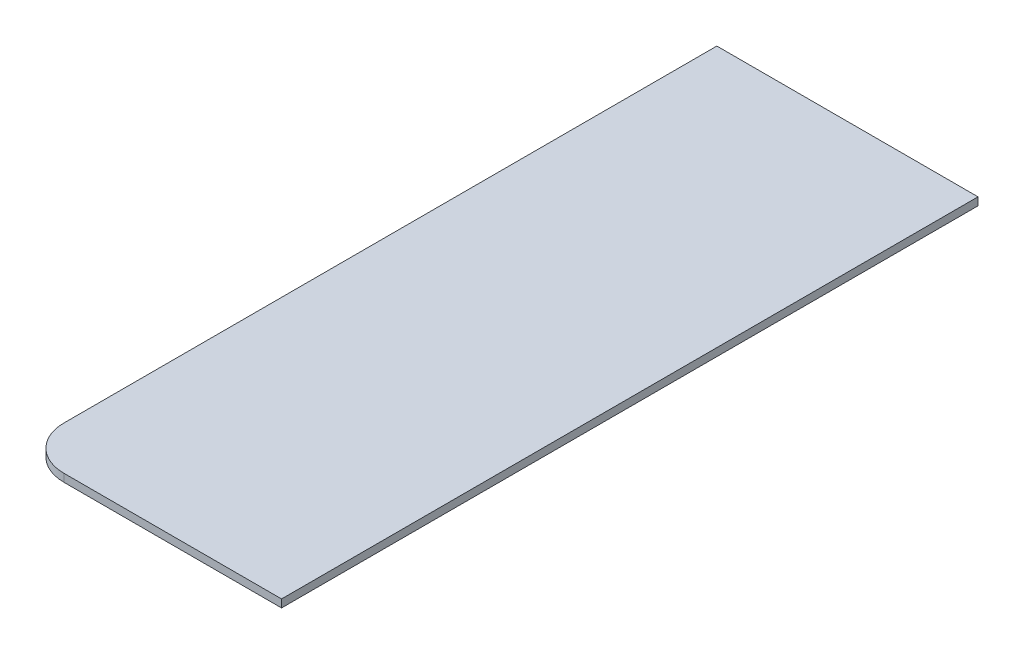
from build123d import *

# Parameters (mm, degrees)
SKETCH_1_W      = 600
SKETCH_1_H      = 1600
EXTRUDE_1_DEPTH = 18
FILLET1_R       = 100


with BuildPart() as part:
    # Эскиз1 → Бобышка-Вытянуть1 (new body)
    with BuildSketch(Plane(origin=(0, 0, 0), x_dir=(1, 0, 0), z_dir=(0, 1, 0))):
        with Locations((1238.244362216, -684.311673364)):
            Rectangle(SKETCH_1_W, SKETCH_1_H)
    extrude(amount=EXTRUDE_1_DEPTH)

    # Fillet1
    fillet1_edges = [part.edges().sort_by_distance(p)[0] for p in [
        (938.244362216, 9, 1484.311673364),
    ]]
    fillet(fillet1_edges, radius=FILLET1_R)


solid = part.part
